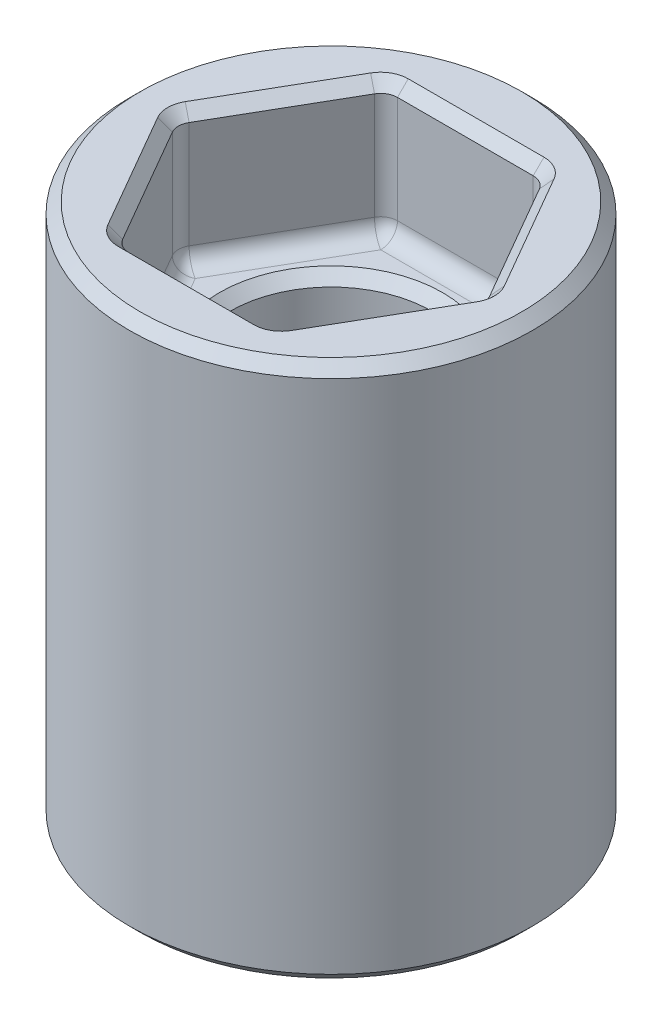
from build123d import *

# Parameters (mm, degrees)
SKETCH4_R           = 4.7625
SKETCH4_R_2         = 1.5875
BOSS_EXTRUDE1_DEPTH = 12.7
CUT_EXTRUDE3_DEPTH  = 3.175
CUT_EXTRUDE2_DEPTH  = 3.175
SKETCH8_R           = 2.38125
CUT_EXTRUDE4_DEPTH  = 3.175
FILLET1_R           = 0.396875
CHAMFER1_SIZE       = 0.254


with BuildPart() as part:
    # Sketch4 → Boss-Extrude1 (new body)
    with BuildSketch(Plane(origin=(0, 0, 0), x_dir=(1, 0, 0), z_dir=(0, 1, 0))):
        Circle(SKETCH4_R)
        Circle(SKETCH4_R_2, mode=Mode.SUBTRACT)
    extrude(amount=BOSS_EXTRUDE1_DEPTH)

    # Sketch7 → Cut-Extrude3 (cut)
    with BuildSketch(Plane.XZ):
        Polygon((1.624115175, 2.81305), (-1.624115175, 2.81305), (-3.248230349, 0), (-1.624115175, -2.81305), (1.624115175, -2.81305), (3.248230349, 0), align=None)
    extrude(amount=-CUT_EXTRUDE3_DEPTH, mode=Mode.SUBTRACT)

    # Sketch6 → Cut-Extrude2 (cut)
    with BuildSketch(Plane(origin=(0, 12.7, 0), x_dir=(1, 0, 0), z_dir=(0, 1, 0))):
        Polygon((1.833087105, 3.175), (-1.833087105, 3.175), (-3.666174209, 0), (-1.833087105, -3.175), (1.833087105, -3.175), (3.666174209, 0), align=None)
    extrude(amount=-CUT_EXTRUDE2_DEPTH, mode=Mode.SUBTRACT)

    # Sketch8 → Cut-Extrude4 (cut)
    with BuildSketch(Plane(origin=(0, 9.525, 0), x_dir=(1, 0, 0), z_dir=(0, 1, 0))):
        Circle(SKETCH8_R)
    extrude(amount=-CUT_EXTRUDE4_DEPTH, mode=Mode.SUBTRACT)

    # Fillet1
    fillet1_edges = [part.edges().sort_by_distance(p)[0] for p in [
        (2.436172762, 3.175, 1.406525),
        (1.624115175, 1.5875, 2.81305),
        (2.436172762, 3.175, -1.406525),
        (3.248230349, 1.5875, 0),
        (0, 3.175, -2.81305),
        (1.624115175, 1.5875, -2.81305),
        (-2.436172762, 3.175, -1.406525),
        (-1.624115175, 1.5875, -2.81305),
        (-2.436172762, 3.175, 1.406525),
        (-3.248230349, 1.5875, 0),
        (0, 3.175, 2.81305),
        (-1.624115175, 1.5875, 2.81305),
        (2.749630657, 9.525, -1.5875),
        (1.833087105, 11.1125, -3.175),
        (2.749630657, 9.525, 1.5875),
        (3.666174209, 11.1125, 0),
        (0, 9.525, 3.175),
        (1.833087105, 11.1125, 3.175),
        (-2.749630657, 9.525, 1.5875),
        (-1.833087105, 11.1125, 3.175),
        (-2.749630657, 9.525, -1.5875),
        (-3.666174209, 11.1125, 0),
        (0, 9.525, -3.175),
        (-1.833087105, 11.1125, -3.175),
        (-2.38125, 6.35, 0),
    ]]
    fillet(fillet1_edges, radius=FILLET1_R)

    # Chamfer1
    chamfer1_edges = [part.edges().sort_by_distance(p)[0] for p in [
        (-1.5875, 3.175, 0),
        (-4.7625, 0, 0),
        (-4.7625, 12.7, 0),
        (-1.5875, 6.35, 0),
        (-2.38125, 9.525, 0),
        (2.436172762, 0, 1.406525),
        (2.436172762, 0, -1.406525),
        (0, 0, -2.81305),
        (-2.436172762, 0, -1.406525),
        (-2.436172762, 0, 1.406525),
        (0, 0, 2.81305),
        (0, 12.7, -3.175),
        (2.749630657, 12.7, -1.5875),
        (-2.749630657, 12.7, 1.5875),
        (-2.749630657, 12.7, -1.5875),
        (0, 12.7, 3.175),
        (2.749630657, 12.7, 1.5875),
        (3.186833573, 0, 0),
        (-1.593416787, 0, -2.759878832),
        (-3.186833573, 0, 0),
        (-1.593416787, 0, 2.759878832),
        (1.593416787, 0, 2.759878832),
        (1.593416787, 0, -2.759878832),
        (1.802388717, 12.7, -3.121828832),
        (-3.604777433, 12.7, 0),
        (-1.802388717, 12.7, 3.121828832),
        (1.802388717, 12.7, 3.121828832),
        (3.604777433, 12.7, 0),
        (-1.802388717, 12.7, -3.121828832),
    ]]
    chamfer(chamfer1_edges, length=CHAMFER1_SIZE)


solid = part.part
